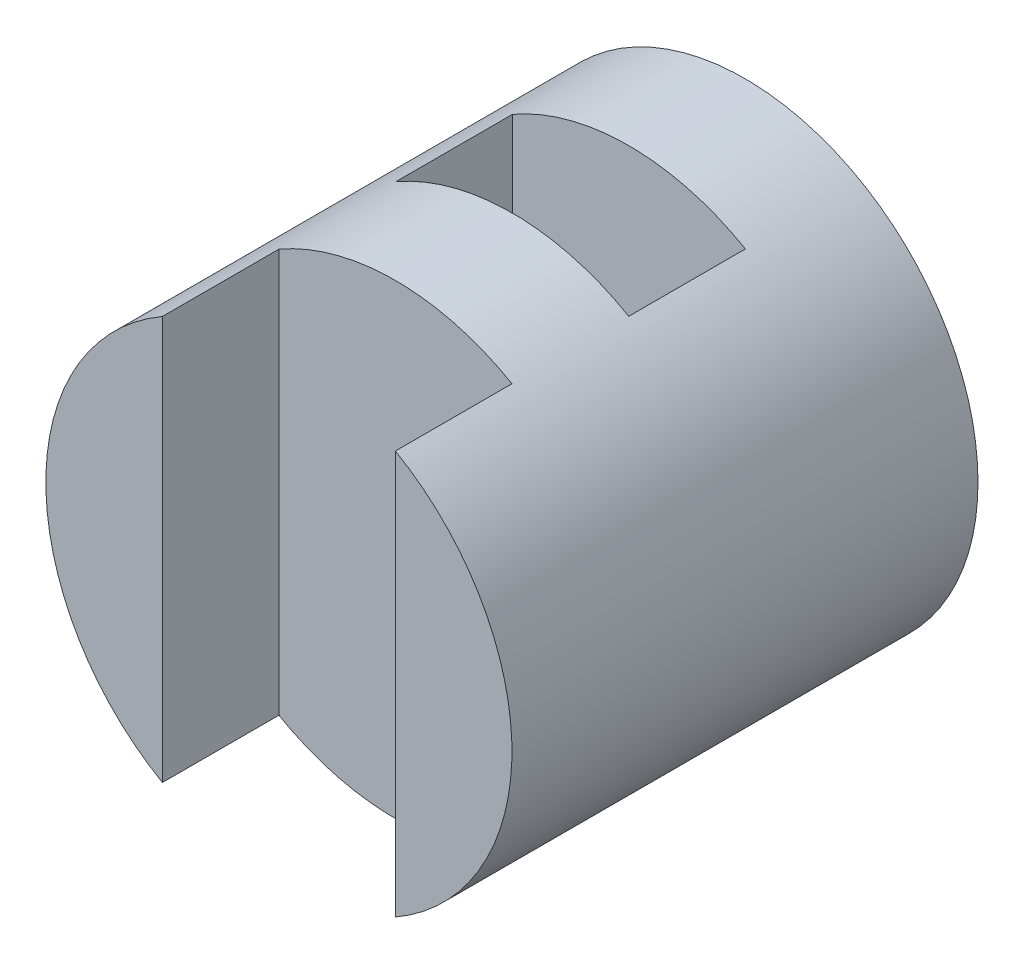
from build123d import *

# Parameters (mm, degrees)
SKETCH1_R           = 2
BOSS_EXTRUDE1_DEPTH = 4
SKETCH2_W           = 2
SKETCH2_H           = 1
SKETCH2_H_2         = 1.000882883
CUT_EXTRUDE1_DEPTH  = 5


with BuildPart() as part:
    # Sketch1 → Boss-Extrude1 (new body)
    with BuildSketch(Plane.XY):
        Circle(SKETCH1_R)
    extrude(amount=BOSS_EXTRUDE1_DEPTH)

    # Sketch2 → Cut-Extrude1 (cut, symmetric)
    with BuildSketch(Plane(origin=(0, 0, 0), x_dir=(1, 0, 0), z_dir=(0, 1, 0))):
        with Locations((0, -3.5)):
            Rectangle(SKETCH2_W, SKETCH2_H)
        with Locations((0, -1.496868109)):
            Rectangle(SKETCH2_W, SKETCH2_H_2)
    extrude(amount=CUT_EXTRUDE1_DEPTH, both=True, mode=Mode.SUBTRACT)


solid = part.part
